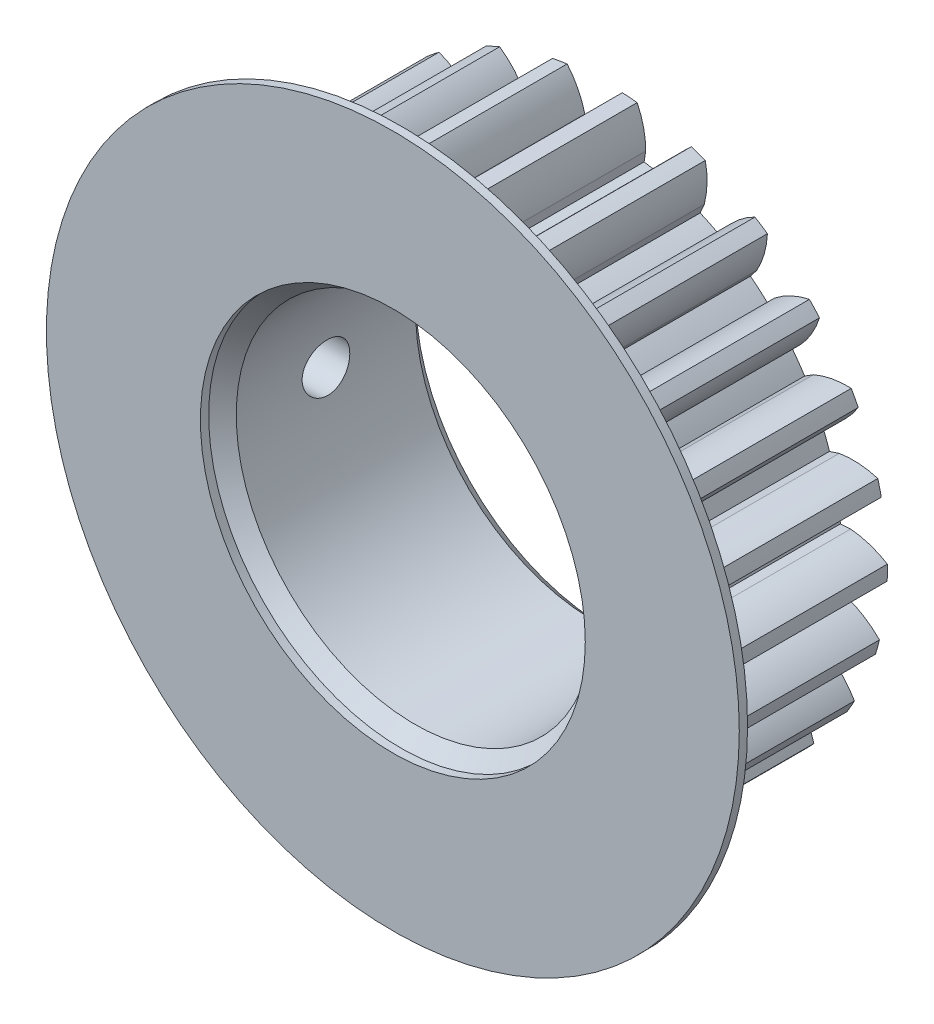
from build123d import *

# Parameters (mm, degrees)
SKETCH2_R                   = 20.25
GEAR_OUTSIDE_DIAMETER_DEPTH = 15
GEAR_TOOTH_CUT_DEPTH        = 33.328393093
GEAR_TEETH_COUNT            = 25
SKETCH3_R                   = 16.875
GEAR_DEDENDUM_CIRCLE_DEPTH  = 15
SKETCH4_R                   = 12.95
CUT_EXTRUDE1_DEPTH          = 33.325524809
CHAMFER1_SIZE               = 1
F_8_32_TAPPED_HOLE1_REACH   = 48.032
F_8_32_TAPPED_HOLE1_BORE_R  = 1.7272
SKETCH6_R                   = 25.11279304
SKETCH6_R_2                 = 13.95
BOSS_EXTRUDE1_DEPTH         = 0.6


with BuildPart() as part:
    # Sketch2 → gear outside diameter (new body)
    with BuildSketch(Plane.XY):
        Circle(SKETCH2_R)
    extrude(amount=GEAR_OUTSIDE_DIAMETER_DEPTH)

    # Sketch1 → gear tooth cut (cut, through all)
    with BuildSketch(Plane.XY):
        with BuildLine():
            Line((0, 17.61923664), (0, 16.875))
            ThreePointArc((0, 16.875), (-0.808466446, 16.855622415), (-1.615076166, 16.797534164))
            Line((-1.615076166, 16.797534164), (-1.686305728, 17.538354334))
            ThreePointArc((-1.686305728, 17.538354334), (-2.181551866, 18.85887247), (-2.96466259, 20.031806602))
            ThreePointArc((-2.96466259, 20.031806602), (-0.970159736, 20.226746898), (1.033844606, 20.223591801))
            ThreePointArc((1.033844606, 20.223591801), (0.36658824, 18.981091972), (0, 17.61923664))
        make_face()
    gear_tooth_cut = extrude(amount=GEAR_TOOTH_CUT_DEPTH, mode=Mode.SUBTRACT)

    # gear teeth: gear tooth cut ×25 about axis
    gear_teeth_axis = Axis((0, 0, 0), (0, 0, 1))
    for i in range(1, GEAR_TEETH_COUNT):
        add(gear_tooth_cut.rotate(gear_teeth_axis, i * 360 / GEAR_TEETH_COUNT), mode=Mode.SUBTRACT)

    # Sketch3 → gear dedendum circle (add)
    with BuildSketch(Plane.XY):
        Circle(SKETCH3_R)
    extrude(amount=GEAR_DEDENDUM_CIRCLE_DEPTH)

    # Sketch4 → Cut-Extrude1 (cut, through all)
    with BuildSketch(Plane.XY.offset(15)):
        Circle(SKETCH4_R)
    extrude(amount=-CUT_EXTRUDE1_DEPTH, mode=Mode.SUBTRACT)

    # Chamfer1
    chamfer1_edges = [part.edges().sort_by_distance(p)[0] for p in [
        (-12.95, 0, 0),
        (-12.95, 0, 15),
    ]]
    chamfer(chamfer1_edges, length=CHAMFER1_SIZE)

    # #8-32 Tapped Hole1 bore (on position points) → #8-32 Tapped Hole1 (cut, up to next)
    with BuildSketch(Plane(origin=(-20.247216374, -0.335751564, 7.5), x_dir=(0.016580324144, -0.999862536978, 0), z_dir=(-0.999862536978, -0.016580324144, 0)), mode=Mode.PRIVATE) as f_8_32_tapped_hole1_sk1:
        Circle(F_8_32_TAPPED_HOLE1_BORE_R)
    f_8_32_tapped_hole1_tool1 = extrude(f_8_32_tapped_hole1_sk1.sketch, amount=-F_8_32_TAPPED_HOLE1_REACH, mode=Mode.PRIVATE) & part.part
    add(f_8_32_tapped_hole1_tool1.solids().sort_by_distance((-20.247216, -0.335752, 7.5))[0], mode=Mode.SUBTRACT)

    # Sketch6 → Boss-Extrude1 (add)
    with BuildSketch(Plane.XY.offset(15)):
        Circle(SKETCH6_R)
        Circle(SKETCH6_R_2, mode=Mode.SUBTRACT)
    extrude(amount=BOSS_EXTRUDE1_DEPTH)


solid = part.part
